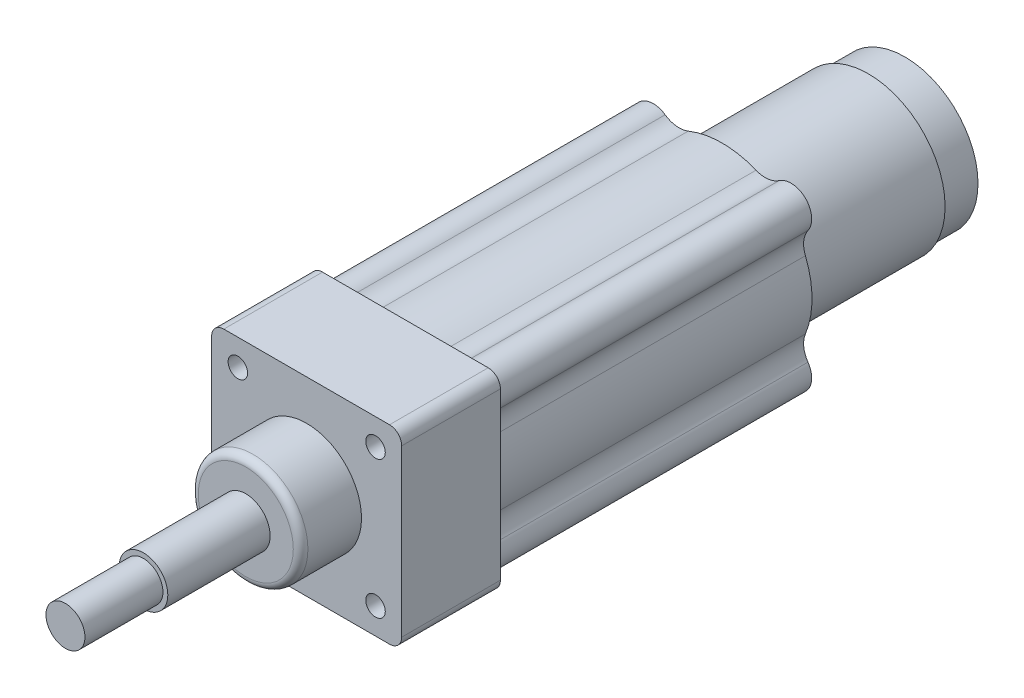
from build123d import *

# Parameters (mm, degrees)
SALIENTE_EXTRUIR1_DEPTH = 40.5
CROQUIS2_R              = 36.886156795
SALIENTE_EXTRUIR2_DEPTH = 170.5
CROQUIS3_R              = 31.5
SALIENTE_EXTRUIR3_DEPTH = 230.5
CROQUIS4_R              = 30
SALIENTE_EXTRUIR4_DEPTH = 15
CROQUIS5_R              = 8.5
SALIENTE_EXTRUIR5_DEPTH = 170.5
REDONDEO2_R             = 10
REDONDEO3_R             = 10
REDONDEO4_R             = 10
REDONDEO5_R             = 10
CROQUIS6_R              = 4
CORTAR_EXTRUIR1_DEPTH   = 17.5
CROQUIS7_R              = 22.5
SALIENTE_EXTRUIR7_DEPTH = 25
REDONDEO6_R             = 3
CROQUIS8_R              = 10
SALIENTE_EXTRUIR8_DEPTH = 42
CROQUIS9_R              = 8
SALIENTE_EXTRUIR9_DEPTH = 32


with BuildPart() as part:
    # Croquis1 → Saliente-Extruir1 (new body)
    with BuildSketch(Plane.XY):
        with BuildLine():
            Line((-34, -39), (34, -39))
            ThreePointArc((34, -39), (37.535533906, -37.535533906), (39, -34))
            Line((39, -34), (39, 34))
            ThreePointArc((39, 34), (37.535533906, 37.535533906), (34, 39))
            Line((34, 39), (-34, 39))
            ThreePointArc((-34, 39), (-37.535533906, 37.535533906), (-39, 34))
            Line((-39, 34), (-39, -34))
            ThreePointArc((-39, -34), (-37.535533906, -37.535533906), (-34, -39))
        make_face()
    extrude(amount=-SALIENTE_EXTRUIR1_DEPTH)

    # Croquis2 → Saliente-Extruir2 (add)
    with BuildSketch(Plane.XY):
        Circle(CROQUIS2_R)
    extrude(amount=-SALIENTE_EXTRUIR2_DEPTH)

    # Croquis3 → Saliente-Extruir3 (add)
    with BuildSketch(Plane.XY):
        Circle(CROQUIS3_R)
    extrude(amount=-SALIENTE_EXTRUIR3_DEPTH)

    # Croquis4 → Saliente-Extruir4 (add)
    with BuildSketch(Plane(origin=(0, 0, -230.5), x_dir=(-1, 0, 0), z_dir=(0, 0, -1))):
        Circle(CROQUIS4_R)
    extrude(amount=SALIENTE_EXTRUIR4_DEPTH)

    # Croquis5 → Saliente-Extruir5 (add)
    with BuildSketch(Plane.XY):
        with Locations((28.25, 28.25)):
            Circle(CROQUIS5_R)
        with Locations((28.25, -28.25)):
            Circle(CROQUIS5_R)
        with Locations((-28.25, -28.25)):
            Circle(CROQUIS5_R)
        with Locations((-28.25, 28.25)):
            Circle(CROQUIS5_R)
    extrude(amount=-SALIENTE_EXTRUIR5_DEPTH)

    # Redondeo2
    redondeo2_edges = [part.edges().sort_by_distance(p)[0] for p in [
        (20.168422903, 30.884029541, -105.5),
        (-20.168422903, 30.884029541, -105.5),
    ]]
    fillet(redondeo2_edges, radius=REDONDEO2_R)

    # Redondeo3
    redondeo3_edges = [part.edges().sort_by_distance(p)[0] for p in [
        (-30.884029541, -20.168422903, -105.5),
        (-30.884029541, 20.168422903, -105.5),
    ]]
    fillet(redondeo3_edges, radius=REDONDEO3_R)

    # Redondeo4
    redondeo4_edges = [part.edges().sort_by_distance(p)[0] for p in [
        (20.168422903, -30.884029541, -105.5),
        (-20.168422903, -30.884029541, -105.5),
    ]]
    fillet(redondeo4_edges, radius=REDONDEO4_R)

    # Redondeo5
    redondeo5_edges = [part.edges().sort_by_distance(p)[0] for p in [
        (30.884029541, 20.168422903, -105.5),
        (30.884029541, -20.168422903, -105.5),
    ]]
    fillet(redondeo5_edges, radius=REDONDEO5_R)

    # Croquis6 → Cortar-Extruir1 (cut)
    with BuildSketch(Plane.XY):
        with Locations((28.25, 28.25)):
            Circle(CROQUIS6_R)
        with Locations((-28.25, 28.25)):
            Circle(CROQUIS6_R)
        with Locations((28.25, -28.25)):
            Circle(CROQUIS6_R)
        with Locations((-28.25, -28.25)):
            Circle(CROQUIS6_R)
    extrude(amount=-CORTAR_EXTRUIR1_DEPTH, mode=Mode.SUBTRACT)

    # Croquis7 → Saliente-Extruir7 (add)
    with BuildSketch(Plane.XY):
        Circle(CROQUIS7_R)
    extrude(amount=SALIENTE_EXTRUIR7_DEPTH)

    # Redondeo6
    redondeo6_edges = [part.edges().sort_by_distance(p)[0] for p in [
        (-22.5, 0, 25),
    ]]
    fillet(redondeo6_edges, radius=REDONDEO6_R)

    # Croquis8 → Saliente-Extruir8 (add)
    with BuildSketch(Plane.XY.offset(25)):
        Circle(CROQUIS8_R)
    extrude(amount=SALIENTE_EXTRUIR8_DEPTH)

    # Croquis9 → Saliente-Extruir9 (add)
    with BuildSketch(Plane.XY.offset(67)):
        Circle(CROQUIS9_R)
    extrude(amount=SALIENTE_EXTRUIR9_DEPTH)


solid = part.part
